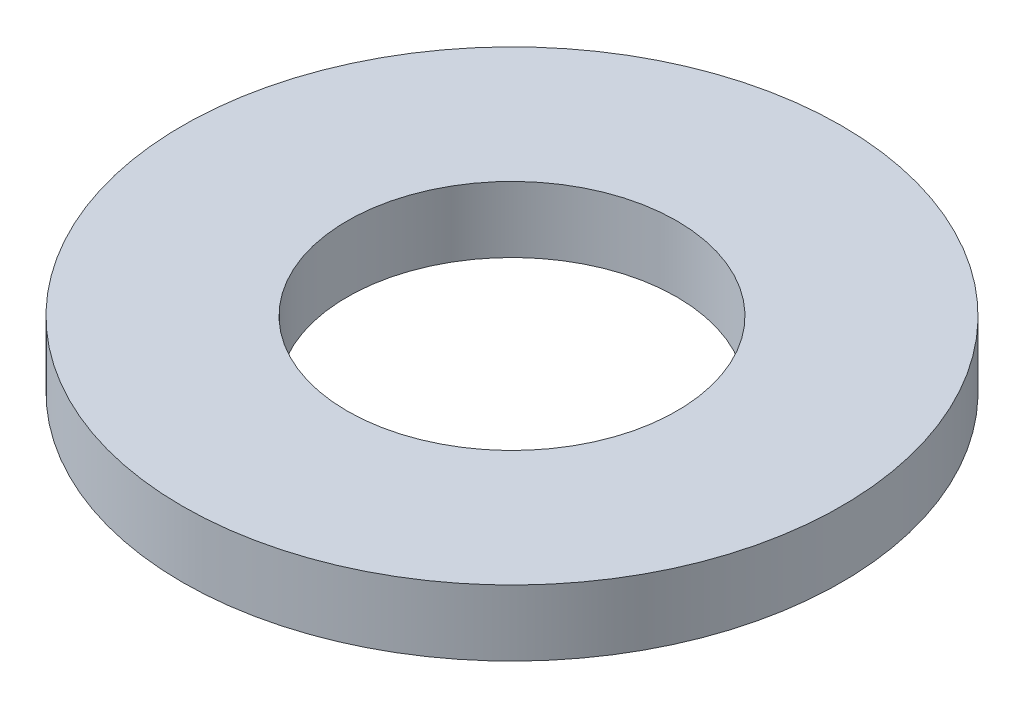
from build123d import *

# Parameters (mm, degrees)
SKETCH1_R           = 5
SKETCH1_R_2         = 2.5
BOSS_EXTRUDE1_DEPTH = 0.5


with BuildPart() as part:
    # Sketch1 → Boss-Extrude1 (new body, symmetric)
    with BuildSketch(Plane(origin=(0, 0, 0), x_dir=(1, 0, 0), z_dir=(0, 1, 0))):
        Circle(SKETCH1_R)
        Circle(SKETCH1_R_2, mode=Mode.SUBTRACT)
    extrude(amount=BOSS_EXTRUDE1_DEPTH, both=True)


solid = part.part
